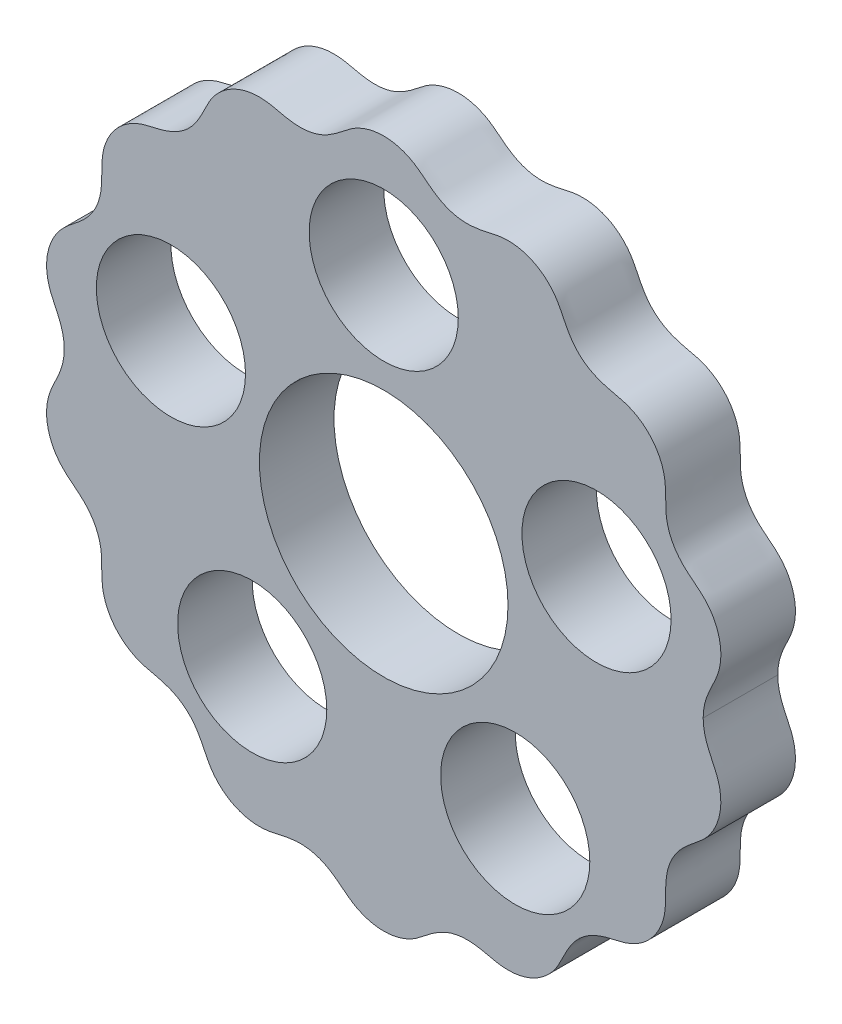
from build123d import *

# Parameters (mm, degrees)
EXTRUDE_1_DEPTH     = 3
SKETCH_2_R          = 5
CUT_EXTRUDE_1_DEPTH = 8
SKETCH_3_R          = 3
CUT_EXTRUDE_2_DEPTH = 3
CUT_EXTRUDE_3_DEPTH = 10


with BuildPart() as part:
    # 草图1 → 凸台-拉伸1 (new body)
    with BuildSketch(Plane.XY):
        with BuildLine():
            add(Edge.make_bspline(
                [(13.000056363, 0), (13.000094523, -0.084569118), (13.012223221, -0.307424814), (13.082647743, -0.66519243), (13.278908146, -1.111490251), (13.525951909, -1.575377307), (13.703368518, -2.138735042), (13.743699185, -2.788019026), (13.603453005, -3.416398132), (13.305604915, -3.968046118), (12.926099261, -4.397545868), (12.571730405, -4.670612264), (12.250657279, -4.9214246), (11.911780089, -5.277626841), (11.686393928, -5.633412725), (11.550075689, -6.033088387), (11.495773859, -6.44659546), (11.487172468, -6.740992767), (11.4935255, -7.074245113), (11.483078663, -7.447696354), (11.395434637, -7.93878741), (11.148618606, -8.510397712), (10.751537763, -9.002150962), (10.23566294, -9.366391804), (9.702705082, -9.581508082), (9.195813842, -9.681182077), (8.616604202, -9.82233721), (8.071802498, -10.13483296), (7.649524343, -10.599743492), (7.386200341, -11.134373076), (7.174466464, -11.605715761), (6.8429511, -12.075281985), (6.371163583, -12.493367149), (5.797318747, -12.769799417), (5.173308871, -12.879940752), (4.665871473, -12.848177571), (4.292458965, -12.767821045), (3.897701625, -12.671006767), (3.420153673, -12.593326461), (2.927906542, -12.63005407), (2.466110665, -12.800244386), (2.110741558, -13.018616582), (1.875440563, -13.197201597), (1.619447724, -13.40965953), (1.321592459, -13.630714773), (0.885046803, -13.863524221), (0.287868734, -14.023170792), (-0.341359331, -14.017579566), (-0.94634974, -13.840267194), (-1.446142781, -13.556559382), (-1.839695339, -13.221944087), (-2.311963193, -12.858038306), (-2.896619868, -12.628519858), (-3.523427085, -12.589932139), (-4.105378244, -12.718533162), (-4.605942967, -12.846202228), (-5.180136083, -12.878469533), (-5.799709763, -12.768969897), (-6.371887585, -12.492625512), (-6.842856877, -12.075419096), (-7.17452902, -11.605627114), (-7.38616177, -11.134422133), (-7.649547954, -10.599721935), (-8.071786638, -10.134835402), (-8.616616524, -9.822353249), (-9.195802423, -9.681140626), (-9.70271796, -9.581585752), (-10.23564534, -9.366268361), (-10.685749304, -9.048815601), (-11.049610121, -8.635219622), (-11.292708717, -8.18280177), (-11.41935248, -7.799890566), (-11.480296297, -7.434770552), (-11.49442576, -7.096932862), (-11.485368171, -6.71678958), (-11.500728872, -6.29244568), (-11.60398156, -5.831163473), (-11.837748763, -5.368670847), (-12.145066205, -5.014100686), (-12.468271559, -4.749757955), (-12.759629632, -4.525721003), (-12.997038223, -4.31255061), (-13.230206048, -4.047117403), (-13.440807245, -3.720666765), (-13.641017361, -3.253456722), (-13.738718335, -2.705065201), (-13.703248693, -2.138681166), (-13.526033997, -1.575415369), (-13.278851078, -1.111463564), (-13.082676807, -0.665206262), (-13.012218137, -0.307422934), (-13.000090562, -0.084568086), (-13.000053952, 0)],
                knots=[0.120528864, 0.120528864, 0.120528864, 0.120528864, 0.120528864, 0.12618534, 0.13542948, 0.144673621, 0.152994416, 0.161315211, 0.174597965, 0.187704176, 0.195264331, 0.202824486, 0.212649435, 0.21756191, 0.222474385, 0.235596752, 0.240509456, 0.245422161, 0.250334865, 0.255247569, 0.262807753, 0.270367936, 0.283474132, 0.296459618, 0.304321335, 0.312183052, 0.321593636, 0.33100422, 0.344001292, 0.353412482, 0.362823671, 0.370685433, 0.378547195, 0.391532655, 0.404567036, 0.412523064, 0.420479093, 0.425283894, 0.430088695, 0.439698297, 0.452744193, 0.457675683, 0.462607173, 0.467538664, 0.472470154, 0.479922308, 0.487374462, 0.500408802, 0.513394297, 0.521256006, 0.529117714, 0.538528229, 0.547938743, 0.560935215, 0.570346764, 0.579758313, 0.587620097, 0.59548188, 0.608467331, 0.621452791, 0.629314553, 0.637176315, 0.646587504, 0.655998694, 0.668995765, 0.67840635, 0.687816934, 0.695678651, 0.703540368, 0.716525854, 0.724297314, 0.732068773, 0.737707919, 0.743347065, 0.748986211, 0.754625357, 0.76314812, 0.771670883, 0.780290081, 0.788909279, 0.794230589, 0.7995519, 0.80487321, 0.81019452, 0.817798277, 0.825402035, 0.838684789, 0.847005584, 0.855326379, 0.86457052, 0.87381466, 0.879471117, 0.879471117, 0.879471117, 0.879471117, 0.879471117], degree=4))
            add(Edge.make_bspline(
                [(13.000056363, 0), (13.000094523, 0.084569118), (13.012223221, 0.307424814), (13.082647743, 0.66519243), (13.278908146, 1.111490251), (13.525951909, 1.575377307), (13.703368518, 2.138735042), (13.743699185, 2.788019026), (13.603453005, 3.416398132), (13.305604915, 3.968046118), (12.926099261, 4.397545868), (12.571730405, 4.670612264), (12.250657279, 4.9214246), (11.911780089, 5.277626841), (11.686393928, 5.633412725), (11.550075689, 6.033088387), (11.495773859, 6.44659546), (11.487172468, 6.740992767), (11.4935255, 7.074245113), (11.483078663, 7.447696354), (11.395434637, 7.93878741), (11.148618606, 8.510397712), (10.751537763, 9.002150962), (10.23566294, 9.366391804), (9.702705082, 9.581508082), (9.195813842, 9.681182077), (8.616604202, 9.82233721), (8.071802498, 10.13483296), (7.649524343, 10.599743492), (7.386200341, 11.134373076), (7.174466464, 11.605715761), (6.8429511, 12.075281985), (6.371163583, 12.493367149), (5.797318747, 12.769799417), (5.173308871, 12.879940752), (4.665871473, 12.848177571), (4.292458965, 12.767821045), (3.897701625, 12.671006767), (3.420153673, 12.593326461), (2.927906542, 12.63005407), (2.466110666, 12.800244386), (2.110741558, 13.018616582), (1.875440563, 13.197201597), (1.619447724, 13.40965953), (1.321592459, 13.630714773), (0.885046803, 13.863524221), (0.287868734, 14.023170792), (-0.341359331, 14.017579566), (-0.94634974, 13.840267194), (-1.446142781, 13.556559382), (-1.839695339, 13.221944087), (-2.311963193, 12.858038306), (-2.896619868, 12.628519858), (-3.523427085, 12.589932139), (-4.105378244, 12.718533162), (-4.605942967, 12.846202228), (-5.180136083, 12.878469533), (-5.799709763, 12.768969897), (-6.371887585, 12.492625512), (-6.842856877, 12.075419096), (-7.17452902, 11.605627114), (-7.38616177, 11.134422133), (-7.649547954, 10.599721935), (-8.071786638, 10.134835402), (-8.616616524, 9.822353249), (-9.195802423, 9.681140626), (-9.70271796, 9.581585752), (-10.23564534, 9.366268361), (-10.685749304, 9.048815601), (-11.049610121, 8.635219622), (-11.292708717, 8.18280177), (-11.41935248, 7.799890566), (-11.480296297, 7.434770552), (-11.49442576, 7.096932862), (-11.485368171, 6.71678958), (-11.500728872, 6.29244568), (-11.60398156, 5.831163473), (-11.837748763, 5.368670847), (-12.145066205, 5.014100686), (-12.468271559, 4.749757955), (-12.759629632, 4.525721003), (-12.997038223, 4.31255061), (-13.230206048, 4.047117403), (-13.440807245, 3.720666765), (-13.641017361, 3.253456722), (-13.738718335, 2.705065201), (-13.703248693, 2.138681167), (-13.526033997, 1.575415369), (-13.278851078, 1.111463564), (-13.082676807, 0.665206262), (-13.012218137, 0.307422934), (-13.000090562, 0.084568086), (-13.000053952, 0)],
                knots=[0.120528864, 0.120528864, 0.120528864, 0.120528864, 0.120528864, 0.12618534, 0.13542948, 0.144673621, 0.152994416, 0.161315211, 0.174597965, 0.187704176, 0.195264331, 0.202824486, 0.212649435, 0.21756191, 0.222474385, 0.235596752, 0.240509456, 0.245422161, 0.250334865, 0.255247569, 0.262807753, 0.270367936, 0.283474132, 0.296459618, 0.304321335, 0.312183052, 0.321593636, 0.33100422, 0.344001292, 0.353412482, 0.362823671, 0.370685433, 0.378547195, 0.391532655, 0.404567036, 0.412523064, 0.420479093, 0.425283894, 0.430088695, 0.439698297, 0.452744193, 0.457675683, 0.462607173, 0.467538664, 0.472470154, 0.479922308, 0.487374462, 0.500408802, 0.513394297, 0.521256006, 0.529117714, 0.538528229, 0.547938743, 0.560935215, 0.570346764, 0.579758313, 0.587620097, 0.59548188, 0.608467331, 0.621452791, 0.629314553, 0.637176315, 0.646587504, 0.655998694, 0.668995765, 0.67840635, 0.687816934, 0.695678651, 0.703540368, 0.716525854, 0.724297314, 0.732068773, 0.737707919, 0.743347065, 0.748986211, 0.754625357, 0.76314812, 0.771670883, 0.780290081, 0.788909279, 0.794230589, 0.7995519, 0.80487321, 0.81019452, 0.817798277, 0.825402035, 0.838684789, 0.847005584, 0.855326379, 0.86457052, 0.87381466, 0.879471117, 0.879471117, 0.879471117, 0.879471117, 0.879471117], degree=4))
        make_face()
    extrude(amount=EXTRUDE_1_DEPTH)

    # 草图2 → 切除-拉伸1 (cut)
    with BuildSketch(Plane.XY.offset(3)):
        Circle(SKETCH_2_R)
    extrude(amount=-CUT_EXTRUDE_1_DEPTH, mode=Mode.SUBTRACT)

    # 草图3 → 切除-拉伸2 (cut)
    with BuildSketch(Plane.XY.offset(3)):
        with Locations((0, 9)):
            Circle(SKETCH_3_R)
        with Locations((8.559508647, 2.781152949)):
            Circle(SKETCH_3_R)
        with Locations((5.290067271, -7.281152949)):
            Circle(SKETCH_3_R)
        with Locations((-5.290067271, -7.281152949)):
            Circle(SKETCH_3_R)
        with Locations((-8.559508647, 2.781152949)):
            Circle(SKETCH_3_R)
    extrude(amount=-CUT_EXTRUDE_2_DEPTH, mode=Mode.SUBTRACT)

    # 草图4 → 切除-拉伸3 (cut)
    with BuildSketch(Plane.XY.offset(3)):
        with BuildLine():
            add(Edge.make_bspline(
                [(13.000056363, 0), (13.000094523, 0.084569118), (13.012223221, 0.307424814), (13.082647743, 0.66519243), (13.278908146, 1.111490251), (13.525951909, 1.575377307), (13.703368518, 2.138735042), (13.743699185, 2.788019026), (13.603453005, 3.416398132), (13.305604915, 3.968046118), (12.926099261, 4.397545868), (12.571730405, 4.670612264), (12.250657279, 4.9214246), (11.911780089, 5.277626841), (11.686393928, 5.633412725), (11.550075689, 6.033088387), (11.495773859, 6.44659546), (11.487172468, 6.740992767), (11.4935255, 7.074245113), (11.483078663, 7.447696354), (11.395434637, 7.93878741), (11.148618606, 8.510397712), (10.751537763, 9.002150962), (10.23566294, 9.366391804), (9.702705082, 9.581508082), (9.195813842, 9.681182077), (8.616604202, 9.82233721), (8.071802498, 10.13483296), (7.649524343, 10.599743492), (7.386200341, 11.134373076), (7.174466464, 11.605715761), (6.8429511, 12.075281985), (6.371163583, 12.493367149), (5.797318747, 12.769799417), (5.173308871, 12.879940752), (4.665871473, 12.848177571), (4.292458965, 12.767821045), (3.897701625, 12.671006767), (3.420153673, 12.593326461), (2.927906542, 12.63005407), (2.466110666, 12.800244386), (2.110741558, 13.018616582), (1.875440563, 13.197201597), (1.619447724, 13.40965953), (1.321592459, 13.630714773), (0.885046803, 13.863524221), (0.287868734, 14.023170792), (-0.341359331, 14.017579566), (-0.94634974, 13.840267194), (-1.446142781, 13.556559382), (-1.839695339, 13.221944087), (-2.311963193, 12.858038306), (-2.896619868, 12.628519858), (-3.523427085, 12.589932139), (-4.105378244, 12.718533162), (-4.605942967, 12.846202228), (-5.180136083, 12.878469533), (-5.799709763, 12.768969897), (-6.371887585, 12.492625512), (-6.842856877, 12.075419096), (-7.17452902, 11.605627114), (-7.38616177, 11.134422133), (-7.649547954, 10.599721935), (-8.071786638, 10.134835402), (-8.616616524, 9.822353249), (-9.195802423, 9.681140626), (-9.70271796, 9.581585752), (-10.23564534, 9.366268361), (-10.685749304, 9.048815601), (-11.049610121, 8.635219622), (-11.292708717, 8.18280177), (-11.41935248, 7.799890566), (-11.480296297, 7.434770552), (-11.49442576, 7.096932862), (-11.485368171, 6.71678958), (-11.500728872, 6.29244568), (-11.60398156, 5.831163473), (-11.837748763, 5.368670847), (-12.145066205, 5.014100686), (-12.468271559, 4.749757955), (-12.759629632, 4.525721003), (-12.997038223, 4.31255061), (-13.230206048, 4.047117403), (-13.440807245, 3.720666765), (-13.641017361, 3.253456722), (-13.738718335, 2.705065201), (-13.703248693, 2.138681167), (-13.526033997, 1.575415369), (-13.278851078, 1.111463564), (-13.082676807, 0.665206262), (-13.012218137, 0.307422934), (-13.000090562, 0.084568086), (-13.000053952, 0)],
                knots=[0.120528864, 0.120528864, 0.120528864, 0.120528864, 0.120528864, 0.12618534, 0.13542948, 0.144673621, 0.152994416, 0.161315211, 0.174597965, 0.187704176, 0.195264331, 0.202824486, 0.212649435, 0.21756191, 0.222474385, 0.235596752, 0.240509456, 0.245422161, 0.250334865, 0.255247569, 0.262807753, 0.270367936, 0.283474132, 0.296459618, 0.304321335, 0.312183052, 0.321593636, 0.33100422, 0.344001292, 0.353412482, 0.362823671, 0.370685433, 0.378547195, 0.391532655, 0.404567036, 0.412523064, 0.420479093, 0.425283894, 0.430088695, 0.439698297, 0.452744193, 0.457675683, 0.462607173, 0.467538664, 0.472470154, 0.479922308, 0.487374462, 0.500408802, 0.513394297, 0.521256006, 0.529117714, 0.538528229, 0.547938743, 0.560935215, 0.570346764, 0.579758313, 0.587620097, 0.59548188, 0.608467331, 0.621452791, 0.629314553, 0.637176315, 0.646587504, 0.655998694, 0.668995765, 0.67840635, 0.687816934, 0.695678651, 0.703540368, 0.716525854, 0.724297314, 0.732068773, 0.737707919, 0.743347065, 0.748986211, 0.754625357, 0.76314812, 0.771670883, 0.780290081, 0.788909279, 0.794230589, 0.7995519, 0.80487321, 0.81019452, 0.817798277, 0.825402035, 0.838684789, 0.847005584, 0.855326379, 0.86457052, 0.87381466, 0.879471117, 0.879471117, 0.879471117, 0.879471117, 0.879471117], degree=4))
            add(Edge.make_bspline(
                [(-13.000053952, 0), (-13.000090562, -0.084568086), (-13.012218137, -0.307422934), (-13.082676807, -0.665206262), (-13.278851078, -1.111463564), (-13.526033997, -1.575415369), (-13.703248693, -2.138681166), (-13.738718335, -2.705065201), (-13.641017361, -3.253456722), (-13.440807245, -3.720666765), (-13.230206048, -4.047117403), (-12.997038223, -4.31255061), (-12.759629632, -4.525721003), (-12.468271559, -4.749757955), (-12.145066205, -5.014100686), (-11.837748763, -5.368670847), (-11.60398156, -5.831163473), (-11.500728872, -6.29244568), (-11.485368171, -6.71678958), (-11.49442576, -7.096932862), (-11.480296297, -7.434770552), (-11.41935248, -7.799890566), (-11.292708717, -8.18280177), (-11.049610121, -8.635219622), (-10.685749304, -9.048815601), (-10.23564534, -9.366268361), (-9.70271796, -9.581585752), (-9.195802423, -9.681140626), (-8.616616524, -9.822353249), (-8.071786638, -10.134835402), (-7.649547954, -10.599721935), (-7.38616177, -11.134422133), (-7.17452902, -11.605627114), (-6.842856877, -12.075419096), (-6.371887585, -12.492625512), (-5.799709763, -12.768969897), (-5.180136083, -12.878469533), (-4.605942967, -12.846202228), (-4.105378244, -12.718533162), (-3.523427085, -12.589932139), (-2.896619868, -12.628519858), (-2.311963193, -12.858038306), (-1.839695339, -13.221944087), (-1.446142781, -13.556559382), (-0.94634974, -13.840267194), (-0.341359331, -14.017579566), (0.287868734, -14.023170792), (0.885046803, -13.863524221), (1.321592459, -13.630714773), (1.619447724, -13.40965953), (1.875440563, -13.197201597), (2.110741558, -13.018616582), (2.466110665, -12.800244386), (2.927906542, -12.63005407), (3.420153673, -12.593326461), (3.897701625, -12.671006767), (4.292458965, -12.767821045), (4.665871473, -12.848177571), (5.173308871, -12.879940752), (5.797318747, -12.769799417), (6.371163583, -12.493367149), (6.8429511, -12.075281985), (7.174466464, -11.605715761), (7.386200341, -11.134373076), (7.649524343, -10.599743492), (8.071802498, -10.13483296), (8.616604202, -9.82233721), (9.195813842, -9.681182077), (9.702705082, -9.581508082), (10.23566294, -9.366391804), (10.751537763, -9.002150962), (11.148618606, -8.510397712), (11.395434637, -7.93878741), (11.483078663, -7.447696354), (11.4935255, -7.074245113), (11.487172468, -6.740992767), (11.495773859, -6.44659546), (11.550075689, -6.033088387), (11.686393928, -5.633412725), (11.911780089, -5.277626841), (12.250657279, -4.9214246), (12.571730405, -4.670612264), (12.926099261, -4.397545868), (13.305604915, -3.968046118), (13.603453005, -3.416398132), (13.743699185, -2.788019026), (13.703368518, -2.138735042), (13.525951909, -1.575377307), (13.278908146, -1.111490251), (13.082647743, -0.66519243), (13.012223221, -0.307424814), (13.000094523, -0.084569118), (13.000056363, 0)],
                knots=[0.120528864, 0.120528864, 0.120528864, 0.120528864, 0.120528864, 0.126185321, 0.135429461, 0.144673602, 0.152994397, 0.161315193, 0.174597946, 0.182201704, 0.189805461, 0.195126771, 0.200448081, 0.205769392, 0.211090702, 0.2197099, 0.228329098, 0.236851861, 0.245374624, 0.25101377, 0.256652916, 0.262292062, 0.267931208, 0.275702668, 0.283474127, 0.296459613, 0.30432133, 0.312183047, 0.321593631, 0.331004216, 0.344001287, 0.353412477, 0.362823667, 0.370685428, 0.37854719, 0.39153265, 0.404518101, 0.412379884, 0.420241668, 0.429653217, 0.439064766, 0.452061238, 0.461471753, 0.470882267, 0.478743975, 0.486605684, 0.499591179, 0.512625519, 0.520077673, 0.527529827, 0.532461317, 0.537392808, 0.542324298, 0.547255788, 0.560301684, 0.569911286, 0.574716087, 0.579520888, 0.587476917, 0.595432945, 0.608467326, 0.621452786, 0.629314548, 0.63717631, 0.646587499, 0.655998689, 0.668995761, 0.678406345, 0.687816929, 0.695678646, 0.703540363, 0.716525849, 0.729632045, 0.737192229, 0.744752412, 0.749665116, 0.754577821, 0.759490525, 0.764403229, 0.777525597, 0.782438071, 0.787350546, 0.797175495, 0.80473565, 0.812295805, 0.825402016, 0.83868477, 0.847005565, 0.85532636, 0.864570501, 0.873814641, 0.879471117, 0.879471117, 0.879471117, 0.879471117, 0.879471117], degree=4))
        make_face()
        with BuildLine():
            add(Edge.make_bspline(
                [(-12.850053938, 0), (-12.850162803, -0.251481731), (-12.940047451, -0.76310762), (-13.28054764, -1.416739482), (-13.533432109, -2.034834319), (-13.607624567, -2.931490894), (-13.293393857, -3.805275711), (-12.660505336, -4.430116027), (-12.07006481, -4.853696993), (-11.587677353, -5.45683705), (-11.341060138, -6.191109664), (-11.342692112, -6.939080539), (-11.324921235, -7.835916299), (-10.903251799, -8.661529711), (-10.199076209, -9.221061058), (-9.579886028, -9.465589196), (-8.874306915, -9.584155876), (-8.164514001, -9.881214163), (-7.59578704, -10.408550559), (-7.245039377, -11.077117507), (-6.959644344, -11.695032177), (-6.508331736, -12.194349494), (-5.935810203, -12.547679821), (-5.284559654, -12.723048616), (-4.617193894, -12.705341623), (-3.941461494, -12.511541297), (-3.179419606, -12.433761602), (-2.427603214, -12.625098215), (-1.797934742, -13.052810457), (-1.275889084, -13.505468114), (-0.666390527, -13.785149497), (-0.000146268, -13.8824447), (0.666675162, -13.785270662), (1.275837398, -13.505173341), (1.797221603, -13.052877422), (2.427993642, -12.625203786), (3.179215251, -12.433975152), (3.942013785, -12.510868897), (4.616642961, -12.705384517), (5.284570426, -12.723247542), (5.935902149, -12.547508693), (6.508270693, -12.194447042), (6.95965701, -11.695009925), (7.245050302, -11.077102582), (7.595782302, -10.408560309), (8.164516739, -9.881197), (8.874317435, -9.584185678), (9.57988726, -9.465534346), (10.19905185, -9.221117151), (10.903304636, -8.661463541), (11.324904022, -7.835955228), (11.342752844, -6.939062638), (11.341081015, -6.191134542), (11.58767338, -5.45683082), (12.070117575, -4.853474514), (12.660239276, -4.429709822), (13.293536242, -3.80557016), (13.607522024, -2.93141733), (13.533490366, -2.034870555), (13.280508371, -1.41670318), (12.940053015, -0.763117721), (12.850169822, -0.251481435), (12.850056348, 0)],
                knots=[0.120527779, 0.120527779, 0.120527779, 0.120527779, 0.132386286, 0.144244793, 0.156103301, 0.167961808, 0.191678823, 0.20353733, 0.215395837, 0.227254345, 0.239112852, 0.250971359, 0.262829867, 0.286546881, 0.298405389, 0.310263896, 0.322122403, 0.333980911, 0.345839418, 0.357697925, 0.369556433, 0.38141494, 0.393273447, 0.405131955, 0.416990462, 0.428848969, 0.440707477, 0.452565984, 0.464424491, 0.476282999, 0.488141506, 0.500000014, 0.511858521, 0.523717028, 0.535575536, 0.547434043, 0.55929255, 0.571151058, 0.583009565, 0.594868072, 0.60672658, 0.618585087, 0.630443594, 0.642302102, 0.654160609, 0.666019116, 0.677877624, 0.689736131, 0.701594638, 0.713453146, 0.73717016, 0.749028668, 0.760887175, 0.772745682, 0.78460419, 0.796462697, 0.808321204, 0.832038219, 0.843896726, 0.855755234, 0.867613741, 0.879472248, 0.879472248, 0.879472248, 0.879472248], degree=3))
            add(Edge.make_bspline(
                [(12.850056348, 0), (12.850169822, 0.251481435), (12.940053015, 0.763117721), (13.280508371, 1.41670318), (13.533490366, 2.034870555), (13.607522024, 2.93141733), (13.293536242, 3.80557016), (12.660239276, 4.429709822), (12.070117575, 4.853474514), (11.58767338, 5.45683082), (11.341081015, 6.191134542), (11.342752844, 6.939062638), (11.324904022, 7.835955228), (10.903304636, 8.661463541), (10.19905185, 9.221117151), (9.57988726, 9.465534346), (8.874317435, 9.584185678), (8.164516739, 9.881197), (7.595782302, 10.408560309), (7.245050302, 11.077102582), (6.95965701, 11.695009925), (6.508270693, 12.194447042), (5.935902149, 12.547508693), (5.284570426, 12.723247542), (4.616642961, 12.705384517), (3.942013785, 12.510868897), (3.179215251, 12.433975152), (2.427993642, 12.625203786), (1.797221603, 13.052877422), (1.275837398, 13.505173341), (0.666675162, 13.785270662), (-0.000146268, 13.8824447), (-0.666390527, 13.785149497), (-1.275889084, 13.505468114), (-1.797934742, 13.052810457), (-2.427603214, 12.625098215), (-3.179419606, 12.433761602), (-3.941461494, 12.511541297), (-4.617193894, 12.705341623), (-5.284559654, 12.723048616), (-5.935810203, 12.547679821), (-6.508331736, 12.194349494), (-6.959644344, 11.695032177), (-7.245039377, 11.077117507), (-7.59578704, 10.408550559), (-8.164514001, 9.881214163), (-8.874306915, 9.584155876), (-9.579886028, 9.465589196), (-10.199076209, 9.221061058), (-10.903251799, 8.661529711), (-11.324921235, 7.835916299), (-11.342692112, 6.939080539), (-11.341060138, 6.191109664), (-11.587677353, 5.45683705), (-12.07006481, 4.853696993), (-12.660505336, 4.430116027), (-13.293393857, 3.805275711), (-13.607624567, 2.931490894), (-13.533432109, 2.034834319), (-13.28054764, 1.416739482), (-12.940047451, 0.76310762), (-12.850162803, 0.251481731), (-12.850053938, 0)],
                knots=[0.120527733, 0.120527733, 0.120527733, 0.120527733, 0.13238624, 0.144244747, 0.156103255, 0.167961762, 0.191678777, 0.203537284, 0.215395791, 0.227254299, 0.239112806, 0.250971313, 0.262829821, 0.286546835, 0.298405343, 0.31026385, 0.322122357, 0.333980865, 0.345839372, 0.357697879, 0.369556387, 0.381414894, 0.393273401, 0.405131909, 0.416990416, 0.428848924, 0.440707431, 0.452565938, 0.464424446, 0.476282953, 0.48814146, 0.499999968, 0.511858475, 0.523716982, 0.53557549, 0.547433997, 0.559292504, 0.571151012, 0.583009519, 0.594868026, 0.606726534, 0.618585041, 0.630443548, 0.642302056, 0.654160563, 0.66601907, 0.677877578, 0.689736085, 0.701594592, 0.7134531, 0.737170114, 0.749028622, 0.760887129, 0.772745636, 0.784604144, 0.796462651, 0.808321158, 0.832038173, 0.84389668, 0.855755188, 0.867613695, 0.879472202, 0.879472202, 0.879472202, 0.879472202], degree=3))
        make_face(mode=Mode.SUBTRACT)
    extrude(amount=-CUT_EXTRUDE_3_DEPTH, mode=Mode.SUBTRACT)


solid = part.part
